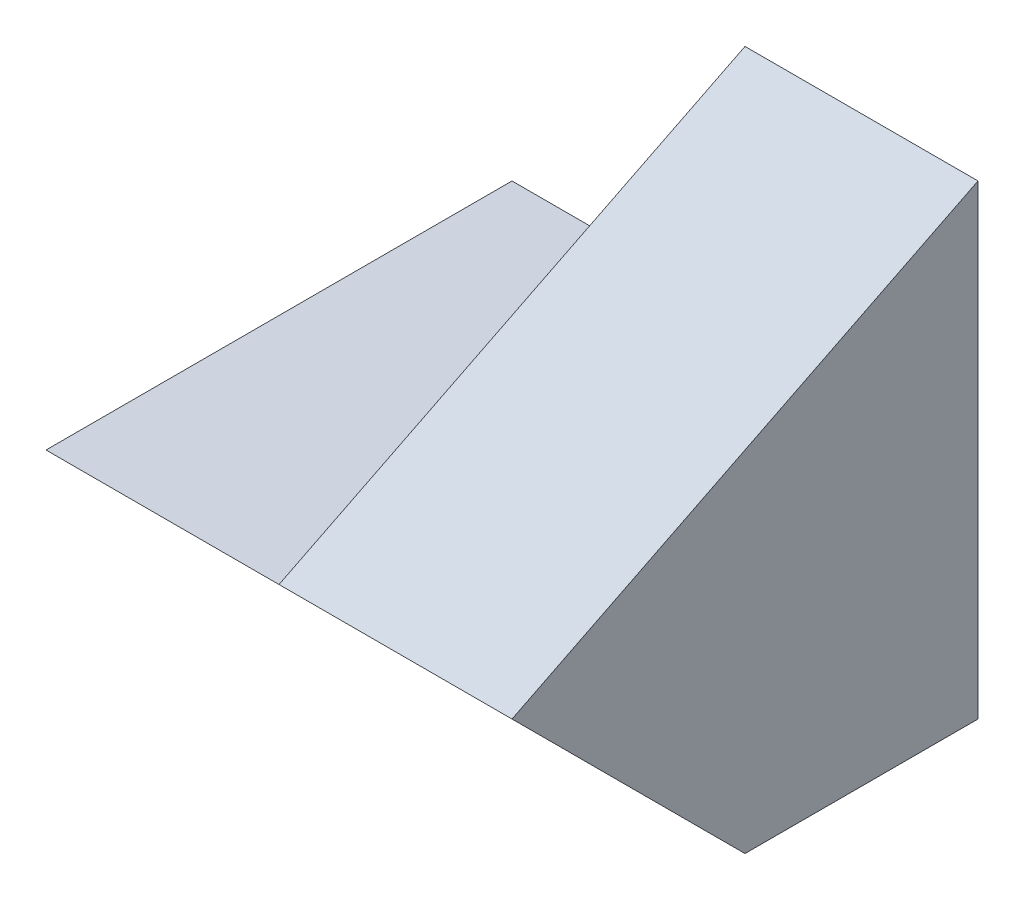
from build123d import *

# Parameters (mm, degrees)
SKETCH1_W           = 40
SKETCH1_H           = 40
BOSS_EXTRUDE1_DEPTH = 40
SKETCH2_W           = 20
SKETCH2_H           = 20
CUT_EXTRUDE1_DEPTH  = 40
CUT_EXTRUDE2_DEPTH  = 40
CUT_EXTRUDE3_DEPTH  = 40


with BuildPart() as part:
    # Sketch1 → Boss-Extrude1 (new body)
    with BuildSketch(Plane.XY):
        with Locations((20, 20)):
            Rectangle(SKETCH1_W, SKETCH1_H)
    extrude(amount=BOSS_EXTRUDE1_DEPTH)

    # Sketch2 → Cut-Extrude1 (cut)
    with BuildSketch(Plane.XY.offset(40)):
        with Locations((10, 30)):
            Rectangle(SKETCH2_W, SKETCH2_H)
    extrude(amount=-CUT_EXTRUDE1_DEPTH, mode=Mode.SUBTRACT)

    # Sketch3 → Cut-Extrude2 (cut)
    with BuildSketch(Plane.ZY.offset(-20)):
        Polygon((0, 40), (40, 20), (40, 40), align=None)
    extrude(amount=-CUT_EXTRUDE2_DEPTH, mode=Mode.SUBTRACT)

    # Sketch4 → Cut-Extrude3 (cut)
    with BuildSketch(Plane.ZY):
        Polygon((40, 20), (20, 0), (40, 0), align=None)
    extrude(amount=-CUT_EXTRUDE3_DEPTH, mode=Mode.SUBTRACT)


solid = part.part
